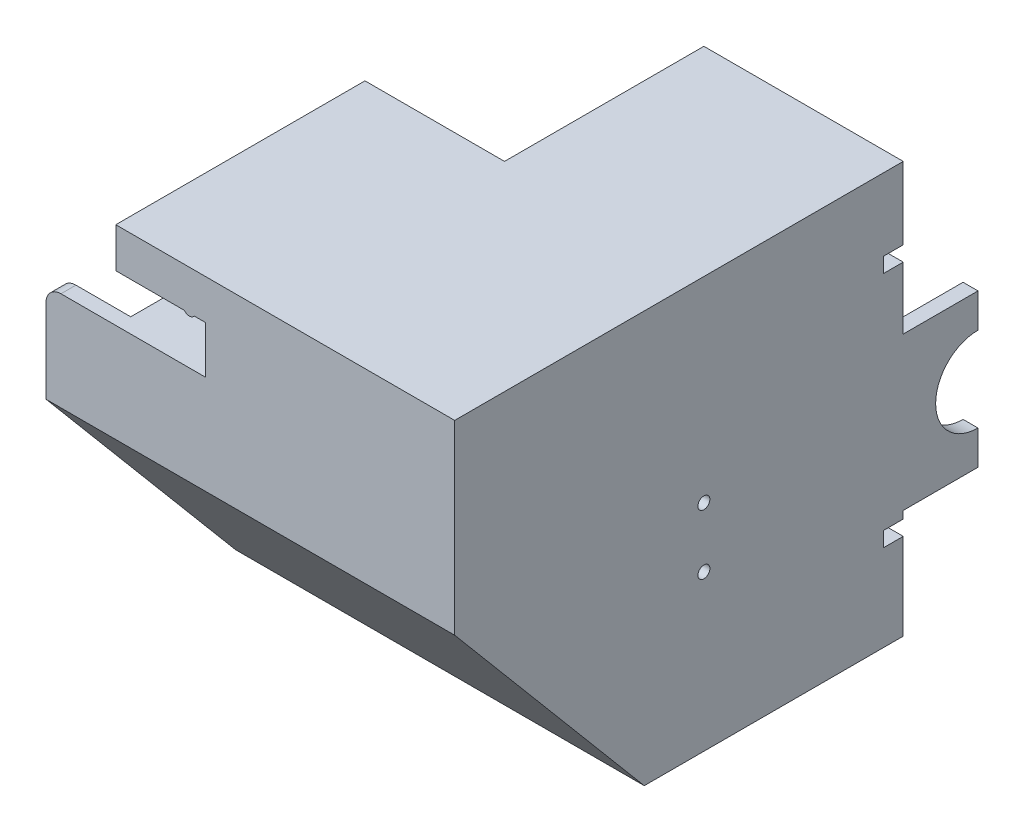
from build123d import *

# Parameters (mm, degrees)
BOSS_EXTRUDE1_DEPTH = 50
SKETCH2_W           = 3
SKETCH2_H           = 22.5
SKETCH2_W_2         = 40
SKETCH2_H_2         = 3
BOSS_EXTRUDE2_DEPTH = 40
SKETCH3_W           = 18
SKETCH3_H           = 9.5
CUT_EXTRUDE1_DEPTH  = 30
SKETCH4_W           = 3
SKETCH4_H           = 90
BOSS_EXTRUDE3_DEPTH = 79.5
SKETCH6_W           = 90
SKETCH6_H           = 3
BOSS_EXTRUDE4_DEPTH = 79
BOSS_EXTRUDE5_DEPTH = 3
FILLET1_R           = 3
SKETCH11_W          = 4
SKETCH11_H          = 3
CUT_EXTRUDE2_DEPTH  = 3
BOSS_EXTRUDE6_DEPTH = 3
SKETCH15_R          = 1.2
SKETCH15_W          = 4
SKETCH15_H          = 3
CUT_EXTRUDE3_DEPTH  = 3
CUT_EXTRUDE4_DEPTH  = 83
BOSS_EXTRUDE7_DEPTH = 82


with BuildPart() as part:
    # Sketch1 → Boss-Extrude1 (new body)
    with BuildSketch(Plane.XY.offset(75.054829109)):
        with BuildLine():
            Line((-97.212578399, 43.970791156), (-83.462578399, 43.970791156))
            ThreePointArc((-83.462578399, 43.970791156), (-82.462578399, 43.470791156), (-81.462578399, 43.970791156))
            Line((-81.462578399, 43.970791156), (-79.212578399, 43.970791156))
            Line((-79.212578399, 43.970791156), (-79.212578399, 34.470791156))
            Line((-79.212578399, 34.470791156), (-97.212578399, 34.470791156))
            Line((-97.212578399, 34.470791156), (-97.212578399, 26.470791156))
            Line((-97.212578399, 26.470791156), (-69.212578399, 26.470791156))
            Line((-69.212578399, 26.470791156), (-69.212578399, 51.970791156))
            Line((-69.212578399, 51.970791156), (-97.212578399, 51.970791156))
            Line((-97.212578399, 51.970791156), (-97.212578399, 43.970791156))
        make_face()
    extrude(amount=BOSS_EXTRUDE1_DEPTH)

    # Sketch2 → Boss-Extrude2 (add)
    with BuildSketch(Plane(origin=(-69.212578399, 0, 0), x_dir=(0, 0, -1), z_dir=(1, 0, 0))):
        with Locations((-123.554829109, 37.720791156)):
            Rectangle(SKETCH2_W, SKETCH2_H)
        Polygon((-75.054829109, 51.970791156), (-125.054829109, 51.970791156), (-125.054829109, 48.970791156), (-122.054829109, 48.970791156), (-75.054829109, 48.970791156), align=None)
        with Locations((-55.054829109, 50.470791156)):
            Rectangle(SKETCH2_W_2, SKETCH2_H_2)
    extrude(amount=BOSS_EXTRUDE2_DEPTH)

    # Sketch3 → Cut-Extrude1 (cut)
    with BuildSketch(Plane(origin=(0, 0, 75.054829109), x_dir=(-1, 0, 0), z_dir=(0, 0, -1))):
        with Locations((88.212578399, 39.220791156)):
            Rectangle(SKETCH3_W, SKETCH3_H)
    extrude(amount=-CUT_EXTRUDE1_DEPTH, mode=Mode.SUBTRACT)

    # Sketch4 → Boss-Extrude3 (add)
    with BuildSketch(Plane.XZ.offset(-48.970791156)):
        with Locations((-30.712578399, 80.054829109)):
            Rectangle(SKETCH4_W, SKETCH4_H)
    extrude(amount=BOSS_EXTRUDE3_DEPTH)

    # Sketch6 → Boss-Extrude4 (add)
    with BuildSketch(Plane.ZY.offset(32.212578399)):
        with Locations((80.054829109, -29.029208844)):
            Rectangle(SKETCH6_W, SKETCH6_H)
    extrude(amount=BOSS_EXTRUDE4_DEPTH)

    # Sketch7 → Boss-Extrude5 (add)
    with BuildSketch(Plane.XY.offset(125.054829109)):
        Polygon((-111.212578399, -27.529208844), (-32.212578399, -27.529208844), (-32.212578399, 26.470791156), (-97.212578399, 26.470791156), (-97.212578399, 34.470791156), (-111.212578399, 34.470791156), align=None)
    extrude(amount=-BOSS_EXTRUDE5_DEPTH)

    # Fillet1
    fillet1_edges = [part.edges().sort_by_distance(p)[0] for p in [
        (-111.212578399, 34.470791156, 123.554829109),
    ]]
    fillet(fillet1_edges, radius=FILLET1_R)

    # Sketch11 → Cut-Extrude2 (cut)
    with BuildSketch(Plane(origin=(-29.212578399, 0, 0), x_dir=(0, 0, -1), z_dir=(1, 0, 0))):
        with Locations((-37.054829109, 35.970791156)):
            Rectangle(SKETCH11_W, SKETCH11_H)
    extrude(amount=-CUT_EXTRUDE2_DEPTH, mode=Mode.SUBTRACT)

    # Sketch13 → Boss-Extrude6 (add)
    with BuildSketch(Plane(origin=(-29.212578399, 0, 0), x_dir=(0, 0, -1), z_dir=(1, 0, 0))):
        with BuildLine():
            Line((-20.054829109, 15.145791156), (-20.054829109, 21.970791156))
            Line((-20.054829109, 21.970791156), (-35.054829109, 21.970791156))
            Line((-35.054829109, 21.970791156), (-35.054829109, -8.679208844))
            Line((-35.054829109, -8.679208844), (-20.054829109, -8.679208844))
            Line((-20.054829109, -8.679208844), (-20.054829109, -1.854208844))
            ThreePointArc((-20.054829109, -1.854208844), (-28.554829109, 6.645791156), (-20.054829109, 15.145791156))
        make_face()
    extrude(amount=-BOSS_EXTRUDE6_DEPTH)

    # Sketch15 → Cut-Extrude3 (cut)
    with BuildSketch(Plane(origin=(-29.212578399, 0, 0), x_dir=(0, 0, -1), z_dir=(1, 0, 0))):
        with Locations((-75.054829109, 0.645791156)):
            Circle(SKETCH15_R)
        with Locations((-75.054829109, 12.645791156)):
            Circle(SKETCH15_R)
        with Locations((-37.054829109, -11.679208844)):
            Rectangle(SKETCH15_W, SKETCH15_H)
    extrude(amount=-CUT_EXTRUDE3_DEPTH, mode=Mode.SUBTRACT)

    # Sketch16 → Cut-Extrude4 (cut, through all)
    with BuildSketch(Plane(origin=(-29.212578399, 0, 0), x_dir=(0, 0, -1), z_dir=(1, 0, 0))):
        Polygon((-125.054829109, 16.970791156), (-85.054829109, -30.529208844), (-125.054829109, -30.529208844), align=None)
    extrude(amount=-CUT_EXTRUDE4_DEPTH, mode=Mode.SUBTRACT)

    # Sketch17 → Boss-Extrude7 (add)
    with BuildSketch(Plane(origin=(-29.212578399, 0, 0), x_dir=(0, 0, -1), z_dir=(1, 0, 0))):
        Polygon((-125.054829109, 19.299492846), (-125.054829109, 14.642089465), (-87.015841059, -30.529208844), (-83.093817159, -30.529208844), align=None)
    extrude(amount=-BOSS_EXTRUDE7_DEPTH)


solid = part.part
